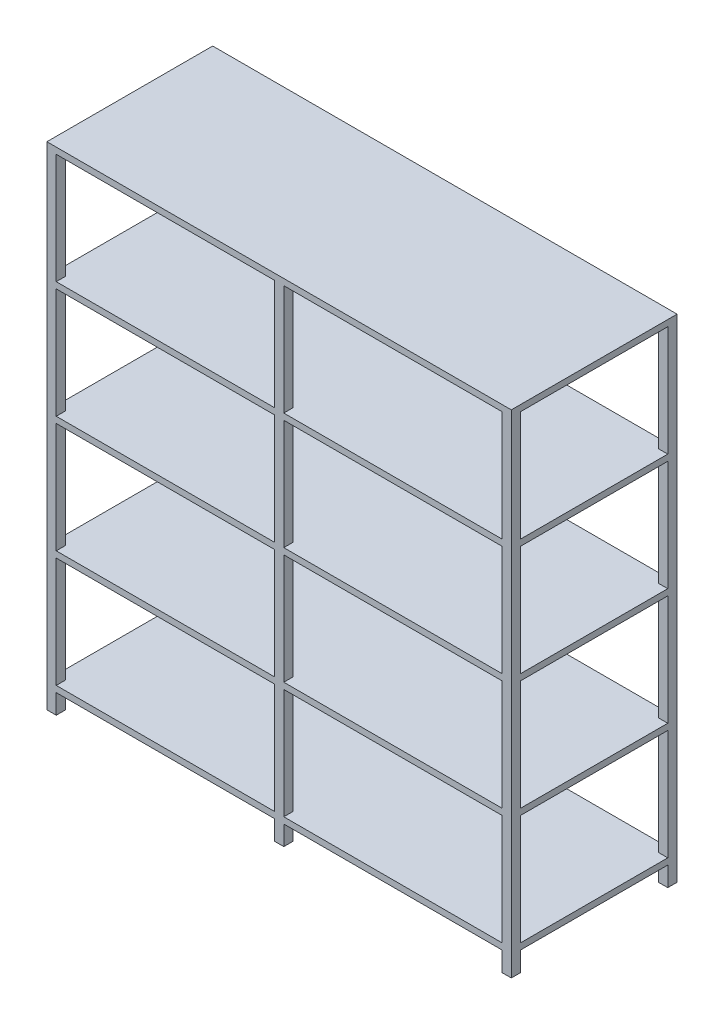
from build123d import *

# Parameters (mm, degrees)
CROQUIS1_W                = 38.1
CROQUIS1_H                = 38.1
SALIENTE_EXTRUIR1_DEPTH   = 80
SALIENTE_EXTRUIR1_2_DEPTH = 80
SALIENTE_EXTRUIR1_3_DEPTH = 80
SALIENTE_EXTRUIR1_4_DEPTH = 80
SALIENTE_EXTRUIR1_5_DEPTH = 80
SALIENTE_EXTRUIR1_6_DEPTH = 80
CROQUIS2_W                = 1894.3
CROQUIS2_H                = 676.2
SALIENTE_EXTRUIR2_DEPTH   = 25.4
CROQUIS3_W                = 38.1
CROQUIS3_H                = 38.1
SALIENTE_EXTRUIR3_DEPTH   = 450
CROQUIS4_W                = 1894.3
CROQUIS4_H                = 676.2
SALIENTE_EXTRUIR4_DEPTH   = 25.4
CROQUIS5_W                = 38.1
CROQUIS5_H                = 38.1
SALIENTE_EXTRUIR5_DEPTH   = 450
CROQUIS6_W                = 1894.3
CROQUIS6_H                = 676.2
SALIENTE_EXTRUIR6_DEPTH   = 25.4
CROQUIS7_W                = 38.1
CROQUIS7_H                = 38.1
SALIENTE_EXTRUIR7_DEPTH   = 450
CROQUIS8_W                = 1894.3
CROQUIS8_H                = 676.2
SALIENTE_EXTRUIR8_DEPTH   = 25.4
CROQUIS9_W                = 38.1
CROQUIS9_H                = 38.1
SALIENTE_EXTRUIR9_DEPTH   = 450
CROQUIS10_W               = 1894.3
CROQUIS10_H               = 676.2
SALIENTE_EXTRUIR10_DEPTH  = 25.4


with BuildPart() as part:
    # Croquis1 → Saliente-Extruir1 (new body)
    with BuildSketch(Plane(origin=(0, 0, 0), x_dir=(1, 0, 0), z_dir=(0, 1, 0))):
        with Locations((19.05, -19.05)):
            Rectangle(CROQUIS1_W, CROQUIS1_H)
    extrude(amount=SALIENTE_EXTRUIR1_DEPTH)



with BuildPart() as body_2:
    # Croquis1 → Saliente-Extruir1 2 (new body)
    with BuildSketch(Plane(origin=(0, 0, 0), x_dir=(1, 0, 0), z_dir=(0, 1, 0))):
        with Locations((947.15, -19.05)):
            Rectangle(CROQUIS1_W, CROQUIS1_H)
    extrude(amount=SALIENTE_EXTRUIR1_2_DEPTH)


with BuildPart() as body_3:
    # Croquis1 → Saliente-Extruir1 3 (new body)
    with BuildSketch(Plane(origin=(0, 0, 0), x_dir=(1, 0, 0), z_dir=(0, 1, 0))):
        with Locations((1875.25, -19.05)):
            Rectangle(CROQUIS1_W, CROQUIS1_H)
    extrude(amount=SALIENTE_EXTRUIR1_3_DEPTH)


with BuildPart() as body_4:
    # Croquis1 → Saliente-Extruir1 4 (new body)
    with BuildSketch(Plane(origin=(0, 0, 0), x_dir=(1, 0, 0), z_dir=(0, 1, 0))):
        with Locations((1875.25, -657.15)):
            Rectangle(CROQUIS1_W, CROQUIS1_H)
    extrude(amount=SALIENTE_EXTRUIR1_4_DEPTH)


with BuildPart() as body_5:
    # Croquis1 → Saliente-Extruir1 5 (new body)
    with BuildSketch(Plane(origin=(0, 0, 0), x_dir=(1, 0, 0), z_dir=(0, 1, 0))):
        with Locations((947.15, -657.15)):
            Rectangle(CROQUIS1_W, CROQUIS1_H)
    extrude(amount=SALIENTE_EXTRUIR1_5_DEPTH)


with BuildPart() as body_6:
    # Croquis1 → Saliente-Extruir1 6 (new body)
    with BuildSketch(Plane(origin=(0, 0, 0), x_dir=(1, 0, 0), z_dir=(0, 1, 0))):
        with Locations((19.05, -657.15)):
            Rectangle(CROQUIS1_W, CROQUIS1_H)
    extrude(amount=SALIENTE_EXTRUIR1_6_DEPTH)


with BuildPart() as part_1:
    add(part.part)

    add(body_2.part)  # Saliente-Extruir2 merges body 2

    add(body_3.part)  # Saliente-Extruir2 merges body 3

    add(body_4.part)  # Saliente-Extruir2 merges body 4

    add(body_5.part)  # Saliente-Extruir2 merges body 5

    add(body_6.part)  # Saliente-Extruir2 merges body 6
    # Croquis2 → Saliente-Extruir2 (add)
    with BuildSketch(Plane(origin=(0, 80, 0), x_dir=(1, 0, 0), z_dir=(0, 1, 0))):
        with Locations((947.15, -338.1)):
            Rectangle(CROQUIS2_W, CROQUIS2_H)
    extrude(amount=SALIENTE_EXTRUIR2_DEPTH)

    # Croquis3 → Saliente-Extruir3 (add)
    with BuildSketch(Plane(origin=(0, 105.4, 0), x_dir=(1, 0, 0), z_dir=(0, 1, 0))):
        with Locations((19.05, -19.05)):
            Rectangle(CROQUIS3_W, CROQUIS3_H)
        with Locations((947.15, -19.05)):
            Rectangle(CROQUIS3_W, CROQUIS3_H)
        with Locations((1875.25, -19.05)):
            Rectangle(CROQUIS3_W, CROQUIS3_H)
        with Locations((1875.25, -657.15)):
            Rectangle(CROQUIS3_W, CROQUIS3_H)
        with Locations((947.15, -657.15)):
            Rectangle(CROQUIS3_W, CROQUIS3_H)
        with Locations((19.05, -657.15)):
            Rectangle(CROQUIS3_W, CROQUIS3_H)
    extrude(amount=SALIENTE_EXTRUIR3_DEPTH)

    # Croquis4 → Saliente-Extruir4 (add)
    with BuildSketch(Plane(origin=(0, 555.4, 0), x_dir=(1, 0, 0), z_dir=(0, 1, 0))):
        with Locations((947.15, -338.1)):
            Rectangle(CROQUIS4_W, CROQUIS4_H)
    extrude(amount=SALIENTE_EXTRUIR4_DEPTH)

    # Croquis5 → Saliente-Extruir5 (add)
    with BuildSketch(Plane(origin=(0, 580.8, 0), x_dir=(1, 0, 0), z_dir=(0, 1, 0))):
        with Locations((19.05, -19.05)):
            Rectangle(CROQUIS5_W, CROQUIS5_H)
        with Locations((947.15, -19.05)):
            Rectangle(CROQUIS5_W, CROQUIS5_H)
        with Locations((1875.25, -19.05)):
            Rectangle(CROQUIS5_W, CROQUIS5_H)
        with Locations((1875.25, -657.15)):
            Rectangle(CROQUIS5_W, CROQUIS5_H)
        with Locations((947.15, -657.15)):
            Rectangle(CROQUIS5_W, CROQUIS5_H)
        with Locations((19.05, -657.15)):
            Rectangle(CROQUIS5_W, CROQUIS5_H)
    extrude(amount=SALIENTE_EXTRUIR5_DEPTH)

    # Croquis6 → Saliente-Extruir6 (add)
    with BuildSketch(Plane(origin=(0, 1030.8, 0), x_dir=(1, 0, 0), z_dir=(0, 1, 0))):
        with Locations((947.15, -338.1)):
            Rectangle(CROQUIS6_W, CROQUIS6_H)
    extrude(amount=SALIENTE_EXTRUIR6_DEPTH)

    # Croquis7 → Saliente-Extruir7 (add)
    with BuildSketch(Plane(origin=(0, 1056.2, 0), x_dir=(1, 0, 0), z_dir=(0, 1, 0))):
        with Locations((19.05, -19.05)):
            Rectangle(CROQUIS7_W, CROQUIS7_H)
        with Locations((947.15, -19.05)):
            Rectangle(CROQUIS7_W, CROQUIS7_H)
        with Locations((1875.25, -19.05)):
            Rectangle(CROQUIS7_W, CROQUIS7_H)
        with Locations((1875.25, -657.15)):
            Rectangle(CROQUIS7_W, CROQUIS7_H)
        with Locations((947.15, -657.15)):
            Rectangle(CROQUIS7_W, CROQUIS7_H)
        with Locations((19.05, -657.15)):
            Rectangle(CROQUIS7_W, CROQUIS7_H)
    extrude(amount=SALIENTE_EXTRUIR7_DEPTH)

    # Croquis8 → Saliente-Extruir8 (add)
    with BuildSketch(Plane(origin=(0, 1506.2, 0), x_dir=(1, 0, 0), z_dir=(0, 1, 0))):
        with Locations((947.15, -338.1)):
            Rectangle(CROQUIS8_W, CROQUIS8_H)
    extrude(amount=SALIENTE_EXTRUIR8_DEPTH)

    # Croquis9 → Saliente-Extruir9 (add)
    with BuildSketch(Plane(origin=(0, 1531.6, 0), x_dir=(1, 0, 0), z_dir=(0, 1, 0))):
        with Locations((19.05, -19.05)):
            Rectangle(CROQUIS9_W, CROQUIS9_H)
        with Locations((947.15, -19.05)):
            Rectangle(CROQUIS9_W, CROQUIS9_H)
        with Locations((1875.25, -19.05)):
            Rectangle(CROQUIS9_W, CROQUIS9_H)
        with Locations((1875.25, -657.15)):
            Rectangle(CROQUIS9_W, CROQUIS9_H)
        with Locations((947.15, -657.15)):
            Rectangle(CROQUIS9_W, CROQUIS9_H)
        with Locations((19.05, -657.15)):
            Rectangle(CROQUIS9_W, CROQUIS9_H)
    extrude(amount=SALIENTE_EXTRUIR9_DEPTH)

    # Croquis10 → Saliente-Extruir10 (add)
    with BuildSketch(Plane(origin=(0, 1981.6, 0), x_dir=(1, 0, 0), z_dir=(0, 1, 0))):
        with Locations((947.15, -338.1)):
            Rectangle(CROQUIS10_W, CROQUIS10_H)
    extrude(amount=SALIENTE_EXTRUIR10_DEPTH)


solid = part_1.part
